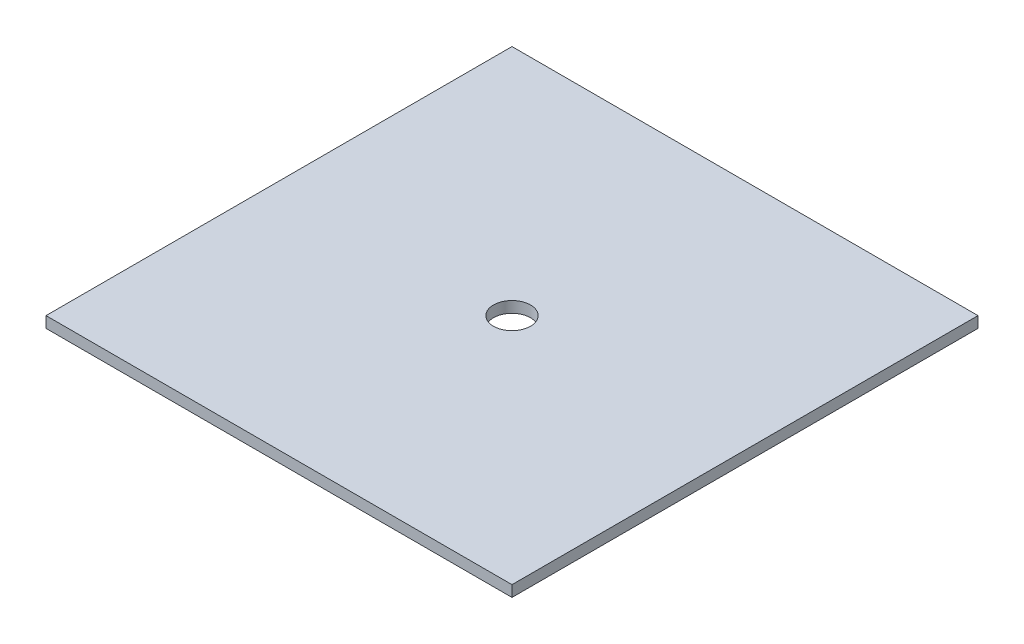
from build123d import *

# Parameters (mm, degrees)
SKETCH1_W           = 200
SKETCH1_H           = 200
SKETCH1_R           = 7.9375
BOSS_EXTRUDE1_DEPTH = 4.7625


with BuildPart() as part:
    # Sketch1 → Boss-Extrude1 (new body)
    with BuildSketch(Plane(origin=(0, 0, 0), x_dir=(1, 0, 0), z_dir=(0, 1, 0))):
        Rectangle(SKETCH1_W, SKETCH1_H)
        Circle(SKETCH1_R, mode=Mode.SUBTRACT)
    extrude(amount=BOSS_EXTRUDE1_DEPTH)


solid = part.part
